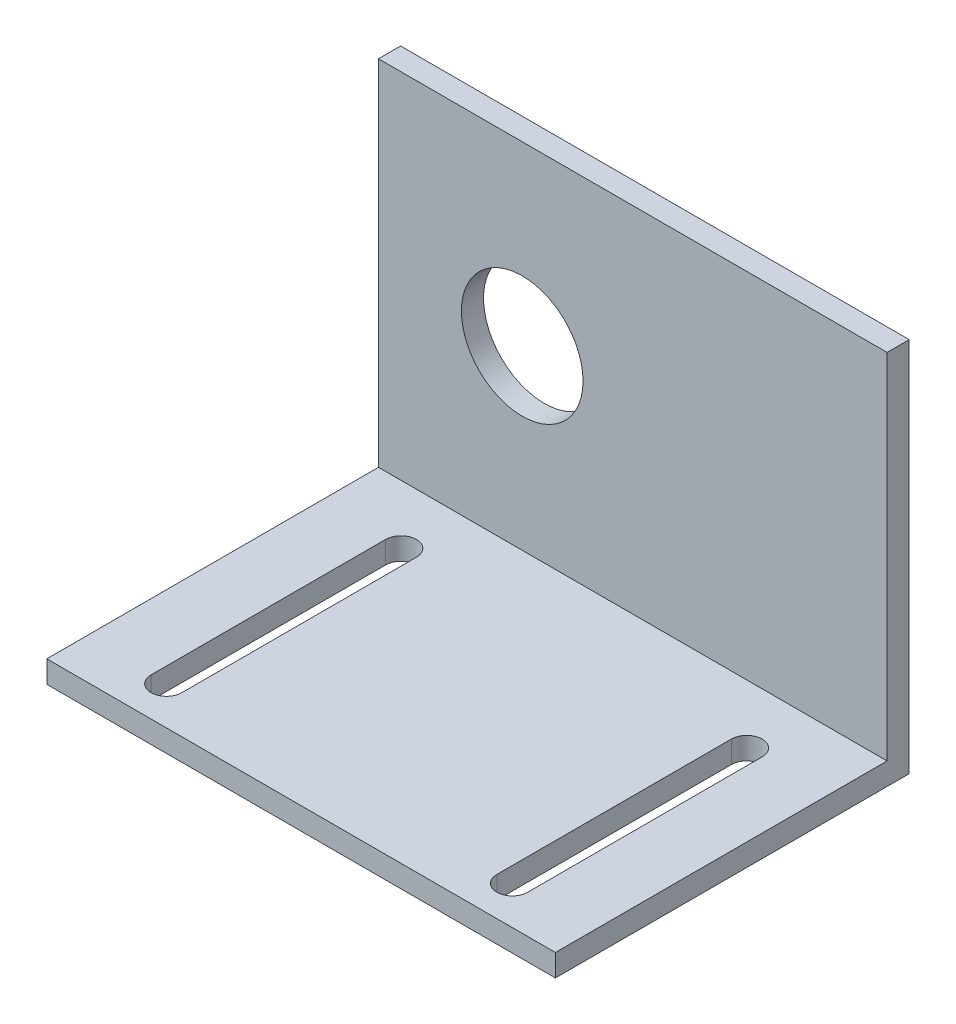
from build123d import *

# Parameters (mm, degrees)
SKETCH_1_W          = 46
SKETCH_1_H          = 34
EXTRUDE_1_DEPTH     = 2
SKETCH_2_W          = 46
SKETCH_2_H          = 2
EXTRUDE_2_DEPTH     = 30
SKETCH_3_R          = 5.5
CUT_EXTRUDE_1_DEPTH = 2
CUT_EXTRUDE_2_DEPTH = 2


with BuildPart() as part:
    # 草图1 → 凸台-拉伸1 (new body)
    with BuildSketch(Plane.XY):
        with Locations((-7.206275861, 17)):
            Rectangle(SKETCH_1_W, SKETCH_1_H)
    extrude(amount=EXTRUDE_1_DEPTH)

    # 草图2 → 凸台-拉伸2 (add)
    with BuildSketch(Plane.XY.offset(2)):
        with Locations((-7.206275861, 1)):
            Rectangle(SKETCH_2_W, SKETCH_2_H)
    extrude(amount=EXTRUDE_2_DEPTH)

    # 草图3 → 切除-拉伸1 (cut)
    with BuildSketch(Plane.XY.offset(2)):
        with Locations((-17.206275861, 18)):
            Circle(SKETCH_3_R)
    extrude(amount=-CUT_EXTRUDE_1_DEPTH, mode=Mode.SUBTRACT)

    # 草图4 → 切除-拉伸2 (cut)
    with BuildSketch(Plane(origin=(0, 2, 0), x_dir=(1, 0, 0), z_dir=(0, 1, 0))):
        with BuildLine():
            Line((-24.235699599, -7.328343443), (-24.235699599, -28.539953108))
            ThreePointArc((-24.235699599, -28.539953108), (-22.841637624, -29.934015083), (-21.447575649, -28.539953108))
            Line((-21.447575649, -28.539953108), (-21.447575649, -7.328343443))
            ThreePointArc((-21.447575649, -7.328343443), (-22.841637624, -5.934281468), (-24.235699599, -7.328343443))
        make_face()
        with BuildLine():
            Line((7.035023927, -7.328343443), (7.035023927, -28.539953108))
            ThreePointArc((7.035023927, -28.539953108), (8.429085903, -29.934015083), (9.823147878, -28.539953108))
            Line((9.823147878, -28.539953108), (9.823147878, -7.328343443))
            ThreePointArc((9.823147878, -7.328343443), (8.429085903, -5.934281468), (7.035023927, -7.328343443))
        make_face()
    extrude(amount=-CUT_EXTRUDE_2_DEPTH, mode=Mode.SUBTRACT)


solid = part.part
